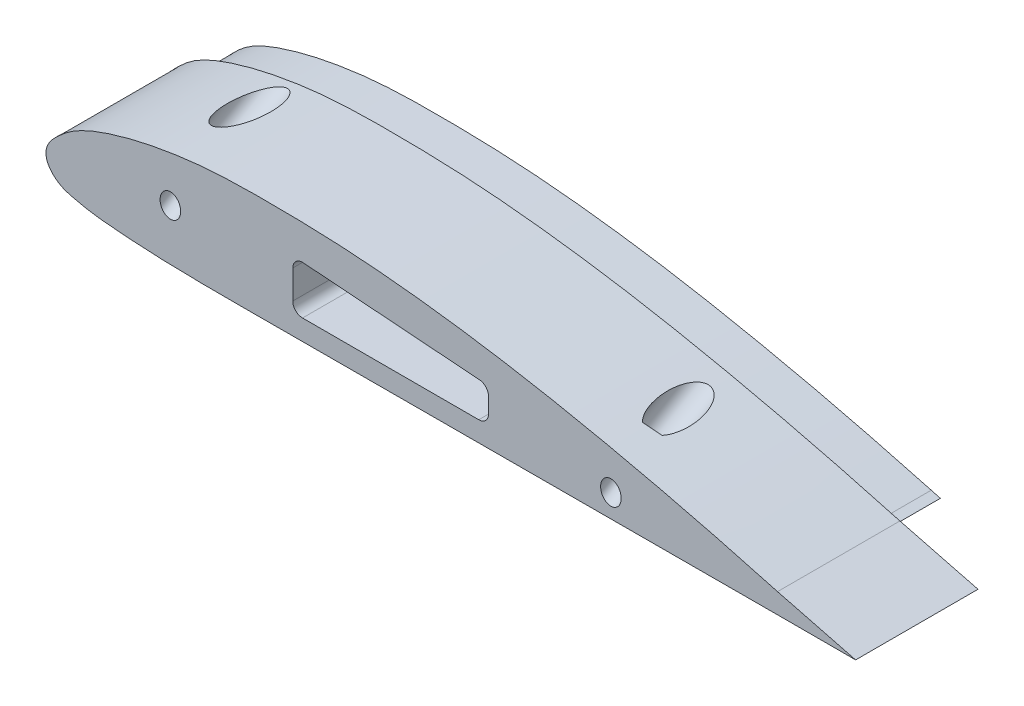
from build123d import *

# Parameters (mm, degrees)
BOSS_EXTRUDE1_DEPTH = 25
BOSS_EXTRUDE2_DEPTH = 10
SKETCH4_R           = 3.6
CUT_EXTRUDE1_DEPTH  = 15
CUT_EXTRUDE3_DEPTH  = 36.0000001
FILLET1_R           = 2
SKETCH7_R           = 3.6
CUT_EXTRUDE5_DEPTH  = 10
SKETCH9_R           = 2.1
CUT_EXTRUDE6_DEPTH  = 38.974026572
SKETCH10_R          = 3.5
CUT_EXTRUDE7_DEPTH  = 25
CUT_EXTRUDE8_DEPTH  = 10


with BuildPart() as part:
    # Sketch1 → Boss-Extrude1 (new body)
    with BuildSketch(Plane.XY):
        with BuildLine():
            Line((283.511495539, 5), (300, 5))
            Line((300, 5), (284.042903706, 9.104747331))
            add(Edge.make_bspline(
                [(284.042903706, 9.104747331), (281.018182266, 9.934448854), (274.970241175, 11.587890144), (262.79473022, 14.694313575), (247.491233442, 18.223533255), (228.976842031, 21.827934197), (213.382227838, 24.050161757), (200.838041916, 25.278245027), (191.375164043, 25.84368073), (181.929184267, 26.032743059), (174.045462371, 26.006042455), (167.684560321, 25.672470841), (162.907071513, 25.190814957), (158.171526473, 24.473110108), (154.249506507, 23.687741972), (151.126214943, 22.914370362), (148.803354307, 22.253406079), (146.502749028, 21.520325526), (144.195506174, 20.673935797), (142.285508901, 19.825366279), (140.77889876, 19.023820525), (139.657125815, 18.333005403), (138.579850724, 17.555983513), (137.573588148, 16.694586159), (136.840207592, 16.017655424), (136.197854945, 15.377866917), (135.703534611, 14.819080651), (135.209742419, 14.135691171), (134.834254268, 13.401317293), (134.617222415, 12.613247879), (134.564446521, 11.925922824), (134.632536136, 11.28393571), (134.823945829, 10.646033518), (135.050340736, 10.171503439), (135.402372545, 9.594086183), (135.88903595, 9.014014422), (136.503170411, 8.453671438), (137.189145836, 7.961236195), (137.934436655, 7.567322512), (138.88780816, 7.188002663), (139.999875909, 6.893687057), (141.119343981, 6.633570858), (142.339822694, 6.362465545), (143.566669583, 6.141759686), (145.201441111, 5.905638988), (147.208483131, 5.701996633), (149.554876985, 5.501790345), (152.720125659, 5.26351314), (156.664468718, 5.054606644), (161.394596408, 4.900355455), (166.115091131, 4.822052763), (170.826943763, 4.793504207), (175.53175108, 4.796790347), (181.792624225, 4.819444757), (189.6120847, 4.833292228), (199.004221884, 4.846116121), (208.393622069, 4.86447262), (217.783394427, 4.881553097), (230.302961737, 4.904736774), (245.952266215, 4.932077157), (264.731689616, 4.966403983), (277.251584666, 4.988082326), (283.511495539, 5)],
                knots=[0, 0, 0, 0, 0.03125, 0.0625, 0.125, 0.1875, 0.25, 0.28125, 0.3125, 0.34375, 0.375, 0.390625, 0.40625, 0.421875, 0.4375, 0.4453125, 0.453125, 0.4609375, 0.46875, 0.4765625, 0.48046875, 0.484375, 0.48828125, 0.4921875, 0.49609375, 0.498046875, 0.5, 0.501953125, 0.50390625, 0.504882812, 0.505859375, 0.506835938, 0.5078125, 0.508789062, 0.509765625, 0.51171875, 0.513671875, 0.515625, 0.517578125, 0.51953125, 0.5234375, 0.52734375, 0.53125, 0.53515625, 0.5390625, 0.546875, 0.5546875, 0.5625, 0.578125, 0.59375, 0.609375, 0.625, 0.640625, 0.65625, 0.6875, 0.71875, 0.75, 0.78125, 0.8125, 0.875, 0.9375, 1, 1, 1, 1], degree=3))
        make_face()
    extrude(amount=BOSS_EXTRUDE1_DEPTH)

    # Sketch2 → Boss-Extrude2 (add)
    with BuildSketch(Plane.XY.offset(25)):
        with BuildLine():
            Line((283.513833939, 7.175995097), (283.507687929, 6.999996376))
            add(Edge.make_bspline(
                [(283.513833939, 7.175995097), (281.571904317, 7.70867951), (278.660206217, 8.507455383), (273.803739367, 9.80565678), (267.97829695, 11.312028336), (262.142072687, 12.749566544), (255.333625933, 14.349614888), (248.529613694, 15.873152186), (237.829834978, 18.074534328), (225.176932927, 20.37341773), (211.498139299, 22.244459108), (201.708098139, 23.182256892), (192.898920041, 23.758329904), (187.019418903, 23.949968323), (180.15742652, 24.013831631), (175.249730247, 24.004272513), (170.338530232, 23.831174476), (165.415432247, 23.461746301), (161.471844656, 22.973662362), (156.530765352, 22.131833865), (152.563801607, 21.260194487), (148.61875975, 20.114158122), (145.614430375, 19.098876324), (143.118037069, 18.029614893), (141.123958755, 16.9205006), (139.709137736, 15.918497883), (138.639345116, 14.95805949), (137.821338999, 14.184645576), (137.299185859, 13.616573145), (136.909881104, 13.064885766), (136.694719435, 12.628458505), (136.558079327, 12.1110472), (136.590613242, 11.681743145), (136.726425076, 11.304303594), (136.875964941, 11.002707479), (137.185565184, 10.559851475), (137.664667186, 10.08522865), (138.418575368, 9.535630723), (139.499520541, 9.074027829), (140.887462138, 8.7435984), (142.345331504, 8.400407996), (143.807660076, 8.124702473), (145.759448913, 7.848569845), (148.205744396, 7.622105414), (151.139287771, 7.379908489), (157.009672693, 7.006958204), (166.81242185, 6.755142002), (180.53899309, 6.823541362), (193.287044915, 6.836259813), (208.977590991, 6.865360258), (224.668134499, 6.894381263), (240.35868648, 6.922785416), (251.145938886, 6.941204055), (259.971867913, 6.958006911), (268.797802015, 6.972991946), (276.643073115, 6.987898539), (281.546370172, 6.996262401), (283.507687929, 6.999996376)],
                knots=[0, 0, 0, 0, 0.020105055, 0.030145261, 0.050190794, 0.080180377, 0.09015591, 0.120020101, 0.149793491, 0.199219015, 0.248395636, 0.287604023, 0.297393127, 0.336534715, 0.346322474, 0.365907652, 0.385530879, 0.395375762, 0.415192461, 0.425184025, 0.445412191, 0.455710779, 0.466190959, 0.477054504, 0.482786727, 0.488945835, 0.494316033, 0.497126416, 0.500187368, 0.502000869, 0.503849971, 0.505020137, 0.507317905, 0.507986558, 0.509023586, 0.510668219, 0.513358348, 0.515715812, 0.519949385, 0.524973188, 0.5299544, 0.534903202, 0.539824123, 0.549630394, 0.559425369, 0.569214167, 0.608355933, 0.657307127, 0.70626328, 0.735636871, 0.813966735, 0.862922864, 0.892296527, 0.921670208, 0.951043871, 0.980417552, 1, 1, 1, 1], degree=3))
        make_face()
    extrude(amount=BOSS_EXTRUDE2_DEPTH)

    # Sketch4 → Cut-Extrude1 (cut)
    with BuildSketch(Plane.XY.offset(35)):
        with Locations((175, 15)):
            Circle(SKETCH4_R)
        with Locations((238.513833939, 12)):
            Circle(SKETCH4_R)
    extrude(amount=-CUT_EXTRUDE1_DEPTH, mode=Mode.SUBTRACT)

    # Sketch5 → Cut-Extrude3 (cut, through all)
    with BuildSketch(Plane.XY.offset(35)):
        Polygon((185, 19), (185, 9), (225, 9), (225, 16), align=None)
    extrude(amount=-CUT_EXTRUDE3_DEPTH, mode=Mode.SUBTRACT)

    # Fillet1
    fillet1_edges = [part.edges().sort_by_distance(p)[0] for p in [
        (185, 19, 17.5),
        (225, 16, 17.5),
        (225, 9, 17.5),
        (185, 9, 17.5),
    ]]
    fillet(fillet1_edges, radius=FILLET1_R)

    # Sketch7 → Cut-Extrude5 (cut)
    with BuildSketch(Plane.XY.offset(20)):
        with Locations((238.513833939, 12)):
            Circle(SKETCH7_R)
        with Locations((175, 15)):
            Circle(SKETCH7_R)
    extrude(amount=-CUT_EXTRUDE5_DEPTH, mode=Mode.SUBTRACT)

    # Sketch9 → Cut-Extrude6 (cut, through all)
    with BuildSketch(Plane(origin=(160, 31.737459239, 28.294012424), x_dir=(-1, 0, 0), z_dir=(0, -0.5, -0.866025404))):
        Circle(SKETCH9_R)
        with Locations((-90, -5)):
            Circle(SKETCH9_R)
    extrude(amount=CUT_EXTRUDE6_DEPTH, mode=Mode.SUBTRACT)

    # Sketch10 → Cut-Extrude7 (cut)
    with BuildSketch(Plane(origin=(160, 31.737459239, 28.294012424), x_dir=(-1, 0, 0), z_dir=(0, -0.5, -0.866025404))):
        Circle(SKETCH10_R)
        with Locations((-90, -5)):
            Circle(SKETCH10_R)
    extrude(amount=CUT_EXTRUDE7_DEPTH, mode=Mode.SUBTRACT)

    # Sketch11 → Cut-Extrude8 (cut)
    with BuildSketch(Plane.XY.offset(35)):
        with BuildLine():
            Line((283.511495539, 5), (300, 5))
            Line((300, 5), (284.042903706, 9.104747331))
            add(Edge.make_bspline(
                [(284.042903706, 9.104747331), (281.018182266, 9.934448854), (274.970241175, 11.587890144), (262.79473022, 14.694313575), (247.491233442, 18.223533255), (228.976842031, 21.827934197), (213.382227838, 24.050161757), (200.838041916, 25.278245027), (191.375164043, 25.84368073), (181.929184267, 26.032743059), (174.045462371, 26.006042455), (167.684560321, 25.672470841), (162.907071513, 25.190814957), (158.171526473, 24.473110108), (154.249506507, 23.687741972), (151.126214943, 22.914370362), (148.803354307, 22.253406079), (146.502749028, 21.520325526), (144.195506174, 20.673935797), (142.285508901, 19.825366279), (140.77889876, 19.023820525), (139.657125815, 18.333005403), (138.579850724, 17.555983513), (137.573588148, 16.694586159), (136.840207592, 16.017655424), (136.197854945, 15.377866917), (135.703534611, 14.819080651), (135.209742419, 14.135691171), (134.834254268, 13.401317293), (134.617222415, 12.613247879), (134.564446521, 11.925922824), (134.632536136, 11.28393571), (134.823945829, 10.646033518), (135.050340736, 10.171503439), (135.402372545, 9.594086183), (135.88903595, 9.014014422), (136.503170411, 8.453671438), (137.189145836, 7.961236195), (137.934436655, 7.567322512), (138.88780816, 7.188002663), (139.999875909, 6.893687057), (141.119343981, 6.633570858), (142.339822694, 6.362465545), (143.566669583, 6.141759686), (145.201441111, 5.905638988), (147.208483131, 5.701996633), (149.554876985, 5.501790345), (152.720125659, 5.26351314), (156.664468718, 5.054606644), (161.394596408, 4.900355455), (166.115091131, 4.822052763), (170.826943763, 4.793504207), (175.53175108, 4.796790347), (181.792624225, 4.819444757), (189.6120847, 4.833292228), (199.004221884, 4.846116121), (208.393622069, 4.86447262), (217.783394427, 4.881553097), (230.302961737, 4.904736774), (245.952266215, 4.932077157), (264.731689616, 4.966403983), (277.251584666, 4.988082326), (283.511495539, 5)],
                knots=[0, 0, 0, 0, 0.03125, 0.0625, 0.125, 0.1875, 0.25, 0.28125, 0.3125, 0.34375, 0.375, 0.390625, 0.40625, 0.421875, 0.4375, 0.4453125, 0.453125, 0.4609375, 0.46875, 0.4765625, 0.48046875, 0.484375, 0.48828125, 0.4921875, 0.49609375, 0.498046875, 0.5, 0.501953125, 0.50390625, 0.504882812, 0.505859375, 0.506835938, 0.5078125, 0.508789062, 0.509765625, 0.51171875, 0.513671875, 0.515625, 0.517578125, 0.51953125, 0.5234375, 0.52734375, 0.53125, 0.53515625, 0.5390625, 0.546875, 0.5546875, 0.5625, 0.578125, 0.59375, 0.609375, 0.625, 0.640625, 0.65625, 0.6875, 0.71875, 0.75, 0.78125, 0.8125, 0.875, 0.9375, 1, 1, 1, 1], degree=3))
        make_face()
        with BuildLine():
            Line((280.513390523, 7.244526695), (282.311215859, 7.247715437))
            Line((282.311215859, 7.247715437), (280.44797449, 7.756537062))
            add(Edge.make_bspline(
                [(280.44797449, 7.756537062), (274.534465518, 9.371422441), (262.666278129, 12.456536483), (244.725070703, 16.500039954), (229.666461352, 19.35987636), (217.545749679, 21.180252708), (208.419827833, 22.292195861), (199.267169335, 23.141591681), (190.090470638, 23.633600144), (180.898070651, 23.789400172), (173.238558093, 23.733636136), (167.129206096, 23.369682896), (162.567763373, 22.874860039), (158.034150221, 22.16074902), (153.539248689, 21.236492218), (149.852487199, 20.234822881), (146.945230118, 19.292315286), (144.803545274, 18.48961438), (142.725540705, 17.546887534), (141.085684909, 16.598722592), (139.86978606, 15.703323679), (139.013550133, 14.961029981), (138.170437688, 14.182154097), (137.401074911, 13.373582652), (136.803307143, 12.444228231), (136.829882646, 11.451768694), (137.482568342, 10.565545947), (138.329478635, 9.869516572), (139.329659123, 9.407251793), (140.415272051, 9.107362954), (141.537321939, 8.847170661), (143.022070654, 8.512295915), (144.899414778, 8.203698196), (147.17695901, 7.963727425), (149.467563487, 7.767177325), (152.519466424, 7.531262629), (156.342190917, 7.321412147), (160.934174151, 7.162916123), (165.530029485, 7.079231042), (171.659516065, 7.034152237), (179.324124736, 7.062229579), (188.524155347, 7.082506373), (197.722784075, 7.093713479), (209.988077557, 7.117662613), (225.319649881, 7.145543289), (243.717600096, 7.178422958), (262.115483697, 7.211491555), (274.380756079, 7.23364945), (280.513390523, 7.244526695)],
                knots=[0.010352061, 0.010352061, 0.010352061, 0.010352061, 0.071582315, 0.132812569, 0.194042822, 0.224657949, 0.255273076, 0.285888203, 0.31650333, 0.347118457, 0.377733584, 0.393041148, 0.408348711, 0.423656275, 0.438963838, 0.454271402, 0.461925183, 0.469578965, 0.477232747, 0.484886529, 0.48871342, 0.49254031, 0.496367201, 0.500194092, 0.504020983, 0.507847874, 0.511674765, 0.515501656, 0.519328547, 0.523155437, 0.526982328, 0.530809219, 0.538463001, 0.546116783, 0.553770564, 0.561424346, 0.57673191, 0.592039473, 0.607347037, 0.6226546, 0.653269727, 0.683884854, 0.714499981, 0.745115108, 0.806345362, 0.867575616, 0.92880587, 0.990036124, 0.990036124, 0.990036124, 0.990036124], degree=3))
        make_face(mode=Mode.SUBTRACT)
    extrude(amount=-CUT_EXTRUDE8_DEPTH, mode=Mode.SUBTRACT)


with BuildPart() as body_2:
    # Mirror1: mirrored copy
    add(part.part.mirror(Plane.XY))


solid = body_2.part
